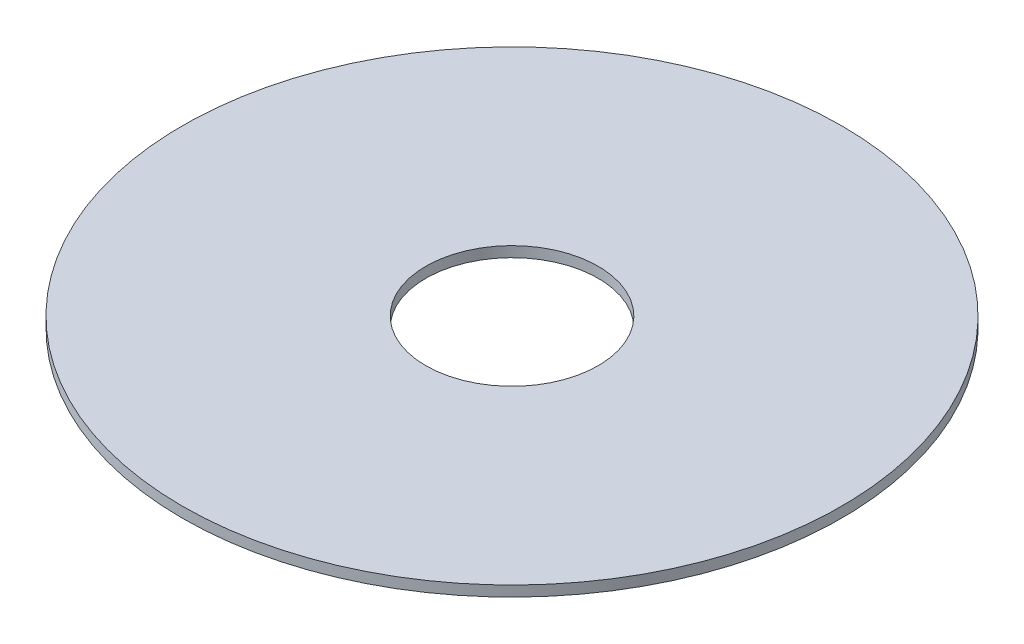
from build123d import *

# Parameters (mm, degrees)
SKETCH1_R           = 53.5344
SKETCH1_R_2         = 14
BOSS_EXTRUDE1_DEPTH = 1.7
SCALE1_SCALE        = 0.5


with BuildPart() as part:
    # Sketch1 → Boss-Extrude1 (new body)
    with BuildSketch(Plane(origin=(0, 0, 0), x_dir=(1, 0, 0), z_dir=(0, 1, 0))):
        Circle(SKETCH1_R)
        Circle(SKETCH1_R_2, mode=Mode.SUBTRACT)
    extrude(amount=BOSS_EXTRUDE1_DEPTH)


with BuildPart() as part_1:
    # Scale1: scaled about (0, 0.85, 0)
    add(part.part.scale(SCALE1_SCALE).moved(Location((0, 0.425, 0))))


solid = part_1.part
